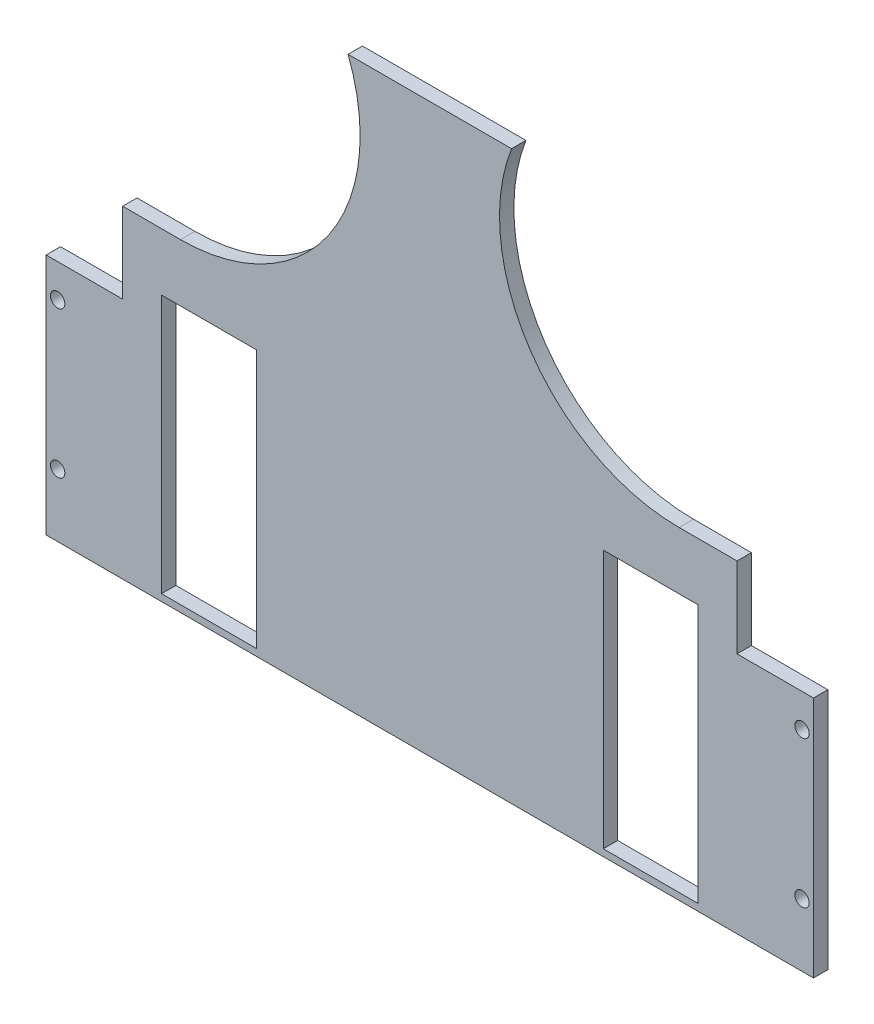
from build123d import *

# Parameters (mm, degrees)
SKETCH1_W           = 267
SKETCH1_H           = 267.4
SKETCH1_R           = 2.5
SKETCH1_W_2         = 33
SKETCH1_H_2         = 90
BOSS_EXTRUDE1_DEPTH = 5
SKETCH6_W           = 267
SKETCH6_H           = 70.024397165
CUT_EXTRUDE4_DEPTH  = 6


with BuildPart() as part:
    # Sketch1 → Boss-Extrude1 (new body)
    with BuildSketch(Plane.XY):
        with Locations((-1087.1, -202.7)):
            Rectangle(SKETCH1_W, SKETCH1_H)
        with Locations((-957.6, -193.5)):
            Circle(SKETCH1_R, mode=Mode.SUBTRACT)
        with Locations((-957.6, -244.5)):
            Circle(SKETCH1_R, mode=Mode.SUBTRACT)
        with Locations((-1216.6, -244.5)):
            Circle(SKETCH1_R, mode=Mode.SUBTRACT)
        with Locations((-1216.6, -193.5)):
            Circle(SKETCH1_R, mode=Mode.SUBTRACT)
        with Locations((-1010.24, -219)):
            Rectangle(SKETCH1_W_2, SKETCH1_H_2, mode=Mode.SUBTRACT)
        with Locations((-1163.96, -219)):
            Rectangle(SKETCH1_W_2, SKETCH1_H_2, mode=Mode.SUBTRACT)
    extrude(amount=BOSS_EXTRUDE1_DEPTH)

    # Sketch6 → Cut-Extrude4 (cut, through all)
    with BuildSketch(Plane.XY.offset(5)):
        with BuildLine():
            Line((-1058.659911457, -69), (-953.6, -69))
            Line((-953.6, -69), (-953.6, -182))
            Line((-953.6, -182), (-980.204338358, -182))
            Line((-980.204338358, -182), (-980.204338358, -154))
            Line((-980.204338358, -154), (-1000.350392508, -154))
            ThreePointArc((-1000.350392508, -154), (-1051.889212828, -126.855339059), (-1058.659911457, -69))
        make_face()
        with Locations((-1087.1, -301.387801417)):
            Rectangle(SKETCH6_W, SKETCH6_H)
        with BuildLine():
            Line((-1115.540088543, -69), (-1220.6, -69))
            Line((-1220.6, -69), (-1220.6, -182))
            Line((-1220.6, -182), (-1193.995661642, -182))
            Line((-1193.995661642, -182), (-1193.995661642, -154))
            Line((-1193.995661642, -154), (-1173.849607492, -154))
            ThreePointArc((-1173.849607492, -154), (-1122.310787172, -126.855339059), (-1115.540088543, -69))
        make_face()
    extrude(amount=-CUT_EXTRUDE4_DEPTH, mode=Mode.SUBTRACT)


solid = part.part
